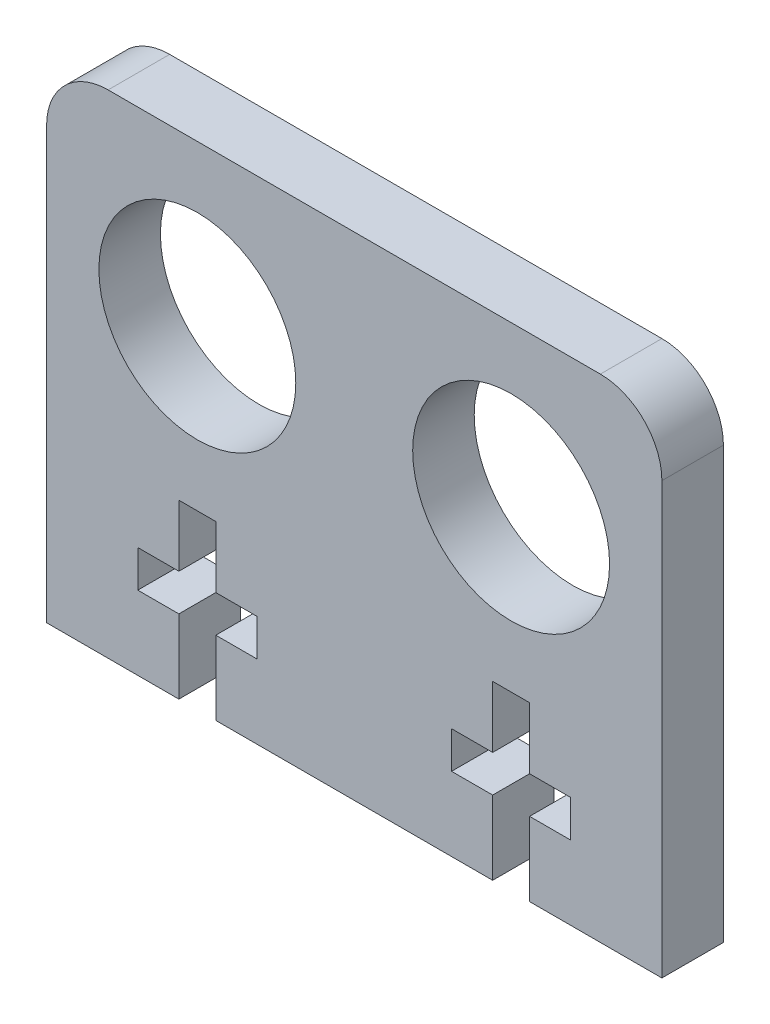
from build123d import *

# Parameters (mm, degrees)
SKETCH1_W           = 50
SKETCH1_H           = 40
BOSS_EXTRUDE1_DEPTH = 5
SKETCH2_R           = 8
CUT_EXTRUDE1_DEPTH  = 5
CUT_EXTRUDE2_DEPTH  = 10
FILLET1_R           = 5
FILLET2_R           = 5


with BuildPart() as part:
    # Sketch1 → Boss-Extrude1 (new body)
    with BuildSketch(Plane.XY):
        with Locations((6.010513563, 6.766366312)):
            Rectangle(SKETCH1_W, SKETCH1_H)
    extrude(amount=BOSS_EXTRUDE1_DEPTH)

    # Sketch2 → Cut-Extrude1 (cut)
    with BuildSketch(Plane(origin=(0, 0, 0), x_dir=(-1, 0, 0), z_dir=(0, 0, -1))):
        with Locations((-18.760103176, 13.766366312)):
            Circle(SKETCH2_R)
        with Locations((6.739896824, 13.766366312)):
            Circle(SKETCH2_R)
    extrude(amount=-CUT_EXTRUDE1_DEPTH, mode=Mode.SUBTRACT)

    # Sketch3 → Cut-Extrude2 (cut)
    with BuildSketch(Plane.XY.offset(5)):
        Polygon((17.260103176, -13.233633688), (20.260103176, -13.233633688), (20.260103176, -7.233633688), (23.600103176, -7.233633688), (23.600103176, -4.233633688), (20.260103176, -4.233633688), (20.260103176, 0.766366312), (17.260103176, 0.766366312), (17.260103176, -4.233633688), (13.920103176, -4.233633688), (13.920103176, -7.233633688), (17.260103176, -7.233633688), align=None)
        Polygon((-8.239896824, -13.233633688), (-5.239896824, -13.233633688), (-5.239896824, -7.233633688), (-1.899896824, -7.233633688), (-1.899896824, -4.233633688), (-5.239896824, -4.233633688), (-5.239896824, 0.766366312), (-8.239896824, 0.766366312), (-8.239896824, -4.233633688), (-11.579896824, -4.233633688), (-11.579896824, -7.233633688), (-8.239896824, -7.233633688), align=None)
    extrude(amount=-CUT_EXTRUDE2_DEPTH, mode=Mode.SUBTRACT)

    # Fillet1
    fillet1_edges = [part.edges().sort_by_distance(p)[0] for p in [
        (-18.989486437, 26.766366312, 2.5),
    ]]
    fillet(fillet1_edges, radius=FILLET1_R)

    # Fillet2
    fillet2_edges = [part.edges().sort_by_distance(p)[0] for p in [
        (31.010513563, 26.766366312, 2.5),
    ]]
    fillet(fillet2_edges, radius=FILLET2_R)


solid = part.part
